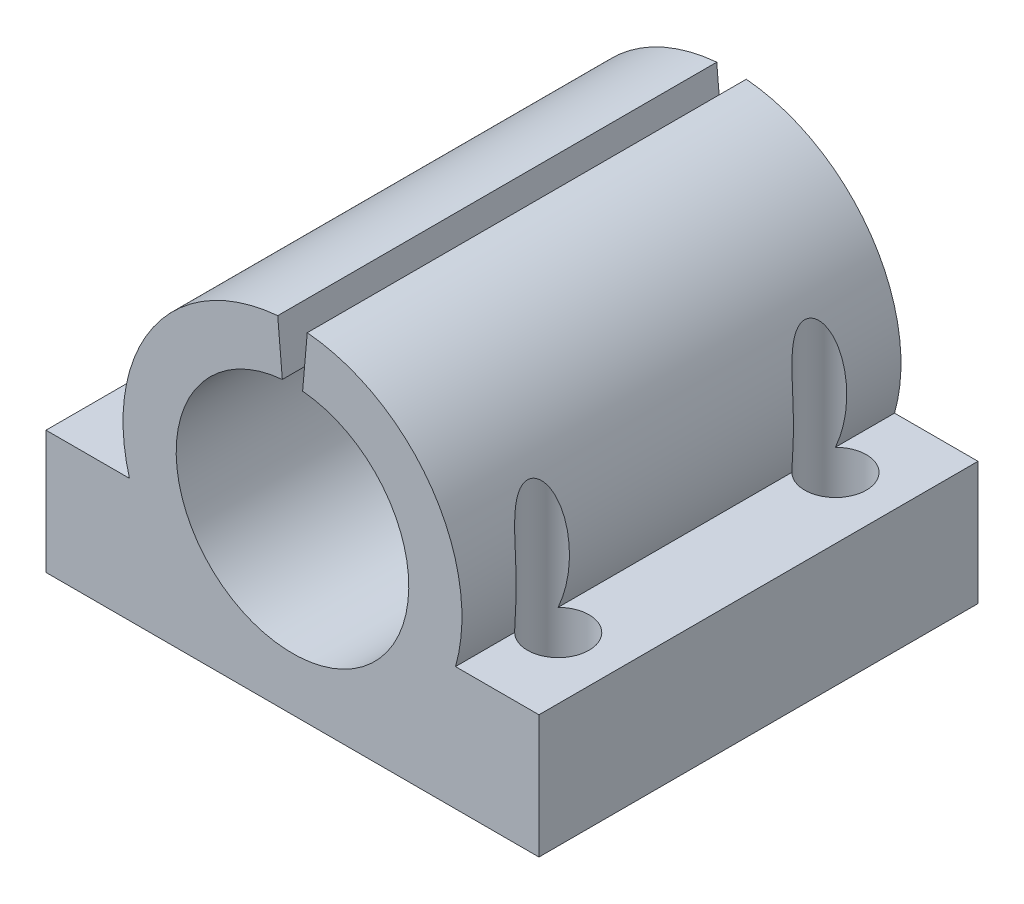
from build123d import *

# Parameters (mm, degrees)
SKETCH1_W               = 32
SKETCH1_H               = 28.5
BOSS_EXTRUDE1_DEPTH     = 8
SKETCH3_R               = 11
BOSS_EXTRUDE2_DEPTH     = 28.5
SKETCH4_R               = 7.55
CUT_EXTRUDE2_DEPTH      = 26.5
SKETCH5_R               = 5
CUT_EXTRUDE3_DEPTH      = 40.398604036
SKETCH2_R               = 2
CUT_EXTRUDE1_DEPTH      = 26.594188794
CUT_EXTRUDE1_DEPTH_BACK = 26.594188794
CUT_EXTRUDE5_DEPTH      = 40.398604164


with BuildPart() as part:
    # Sketch1 → Boss-Extrude1 (new body)
    with BuildSketch(Plane(origin=(0, 0, 0), x_dir=(1, 0, 0), z_dir=(0, 1, 0))):
        Rectangle(SKETCH1_W, SKETCH1_H)
    extrude(amount=BOSS_EXTRUDE1_DEPTH)

    # Sketch3 → Boss-Extrude2 (add, through all)
    with BuildSketch(Plane.XY.offset(14.25)):
        with Locations((0, 11)):
            Circle(SKETCH3_R)
    extrude(amount=-BOSS_EXTRUDE2_DEPTH)

    # Sketch4 → Cut-Extrude2 (cut)
    with BuildSketch(Plane.XY.offset(14.25)):
        with Locations((0, 11)):
            Circle(SKETCH4_R)
    extrude(amount=-CUT_EXTRUDE2_DEPTH, mode=Mode.SUBTRACT)

    # Sketch5 → Cut-Extrude3 (cut, through all)
    with BuildSketch(Plane(origin=(0, 0, -14.25), x_dir=(-1, 0, 0), z_dir=(0, 0, -1))):
        with Locations((0, 11)):
            Circle(SKETCH5_R)
    extrude(amount=-CUT_EXTRUDE3_DEPTH, mode=Mode.SUBTRACT)

    # Sketch2 → Cut-Extrude1 (cut, two sides)
    with BuildSketch(Plane(origin=(0, 8, 0), x_dir=(1, 0, 0), z_dir=(0, 1, 0))) as cut_extrude1_sk:
        with Locations(Location((-12, 9, 0), (0, 0, 270))):
            Circle(SKETCH2_R)
        with Locations(Location((-12, -9, 0), (0, 0, 315.112762264))):
            Circle(SKETCH2_R)
        with Locations(Location((12, -9, 0), (0, 0, 270))):
            Circle(SKETCH2_R)
        with Locations(Location((12, 9, 0), (0, 0, 224.887210993))):
            Circle(SKETCH2_R)
    extrude(amount=CUT_EXTRUDE1_DEPTH, mode=Mode.SUBTRACT)
    extrude(cut_extrude1_sk.sketch, amount=-CUT_EXTRUDE1_DEPTH_BACK, mode=Mode.SUBTRACT)

    # Sketch7 → Cut-Extrude5 (cut, through all)
    with BuildSketch(Plane.XY.offset(14.25)):
        with BuildLine():
            Line((-0.435778714, 15.98097349), (-0.95871317, 21.958141679))
            ThreePointArc((-0.95871317, 21.958141679), (0, 22), (0.95871317, 21.958141679))
            Line((0.95871317, 21.958141679), (0.435778714, 15.98097349))
            ThreePointArc((0.435778714, 15.98097349), (0, 16), (-0.435778714, 15.98097349))
        make_face()
    extrude(amount=-CUT_EXTRUDE5_DEPTH, mode=Mode.SUBTRACT)


solid = part.part
